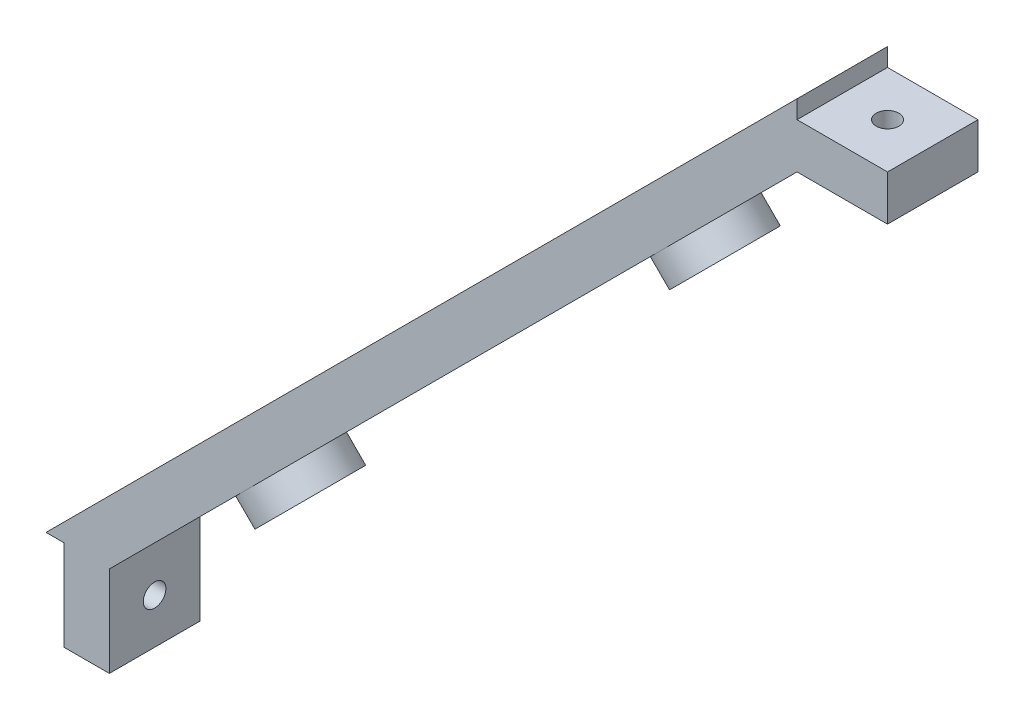
from build123d import *

# Parameters (mm, degrees)
MAIN_DEPTH          = 5
SKETCH2_R           = 1.25
FIXHOLE1_DEPTH      = 84
SKETCH3_R           = 1.25
FIXHOLE2_DEPTH      = 84
SKETCH6_R           = 1.25
CUT_EXTRUDE2_DEPTH  = 64.639610307
LPATTERN1_COUNT     = 5
LPATTERN1_PITCH     = 20
SKETCH7_R           = 5
BOSS_EXTRUDE1_DEPTH = 3
SKETCH8_R           = 1.25
CUT_EXTRUDE3_DEPTH  = 67.639610307


with BuildPart() as part:
    # Sketch1 → Main (new body, symmetric)
    with BuildSketch(Plane.XY):
        Polygon((-41.5, -41.5), (41.5, 41.5), (41.5, 39.5), (51.5, 39.5), (51.5, 34.5), (41.5, 34.5), (-34.5, -41.5), (-34.5, -51.5), (-39.5, -51.5), (-39.5, -41.5), align=None)
    extrude(amount=MAIN_DEPTH, both=True)

    # Sketch2 → FixHole1 (cut, through all)
    with BuildSketch(Plane(origin=(41.5, 0, 0), x_dir=(0, 0, -1), z_dir=(1, 0, 0))):
        with Locations((0, -46.5)):
            Circle(SKETCH2_R)
    extrude(amount=-FIXHOLE1_DEPTH, mode=Mode.SUBTRACT)

    # Sketch3 → FixHole2 (cut, through all)
    with BuildSketch(Plane(origin=(0, -41.5, 0), x_dir=(-1, 0, 0), z_dir=(0, -1, 0))):
        with Locations((-46.5, 0)):
            Circle(SKETCH3_R)
    extrude(amount=-FIXHOLE2_DEPTH, mode=Mode.SUBTRACT)

    # Sketch6 → Cut-Extrude2 (cut, through all)
    with BuildSketch(Plane(origin=(3.5, -3.5, 0), x_dir=(0, 0, 1), z_dir=(-0.707106781, 0.707106781, 0))):
        with Locations((0, 40)):
            Circle(SKETCH6_R)
    cut_extrude2 = extrude(amount=CUT_EXTRUDE2_DEPTH, mode=Mode.SUBTRACT)

    # LPattern1: Cut-Extrude2 ×5
    with Locations(*[Vector(-0.707106781, -0.707106781, 0) * (i * LPATTERN1_PITCH) for i in range(1, LPATTERN1_COUNT)]):
        add(cut_extrude2, mode=Mode.SUBTRACT)

    # Sketch7 → Boss-Extrude1 (add)
    with BuildSketch(Plane(origin=(3.5, -3.5, 0), x_dir=(0, 0, 1), z_dir=(-0.707106781, 0.707106781, 0))):
        with Locations((0, -32.4)):
            Circle(SKETCH7_R)
        with Locations((0, 32.4)):
            Circle(SKETCH7_R)
    extrude(amount=-BOSS_EXTRUDE1_DEPTH)

    # Sketch8 → Cut-Extrude3 (cut, through all)
    with BuildSketch(Plane(origin=(5.621320344, -5.621320344, 0), x_dir=(0, 0, -1), z_dir=(0.707106781, -0.707106781, 0))):
        with Locations((0, 32.4)):
            Circle(SKETCH8_R)
        with Locations((0, -32.4)):
            Circle(SKETCH8_R)
    extrude(amount=-CUT_EXTRUDE3_DEPTH, mode=Mode.SUBTRACT)


solid = part.part
